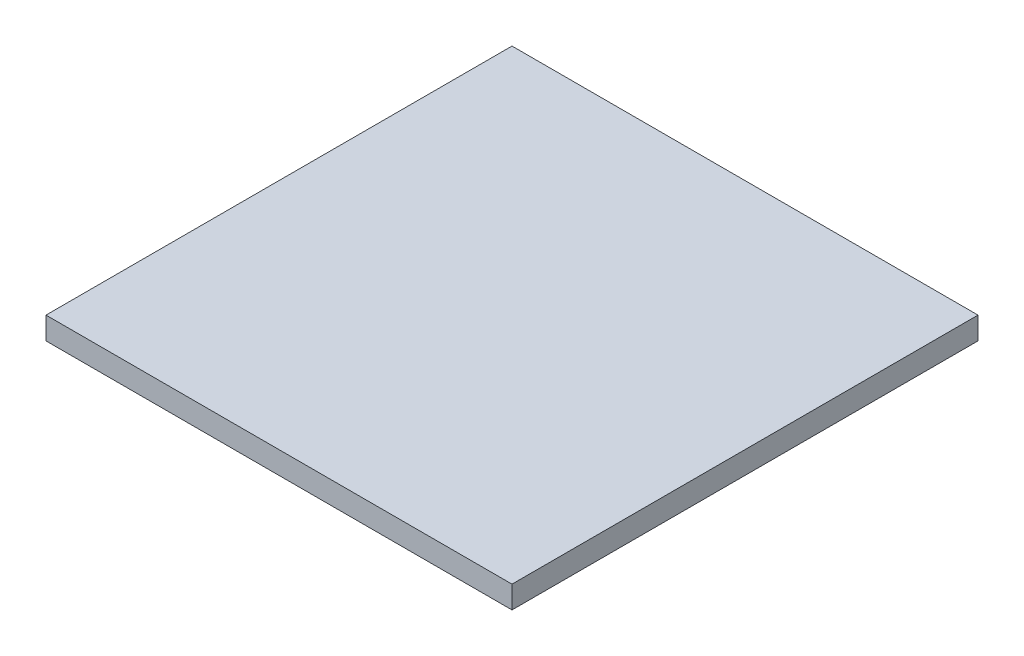
from build123d import *

# Parameters (mm, degrees)
SKETCH1_W           = 250
SKETCH1_H           = 250
BOSS_EXTRUDE1_DEPTH = 12
SKETCH2_R           = 3.5
CUT_EXTRUDE1_DEPTH  = 3


with BuildPart() as part:
    # Sketch1 → Boss-Extrude1 (new body)
    with BuildSketch(Plane(origin=(0, 0, 0), x_dir=(1, 0, 0), z_dir=(0, 1, 0))):
        Rectangle(SKETCH1_W, SKETCH1_H)
    extrude(amount=BOSS_EXTRUDE1_DEPTH)

    # Sketch2 → Cut-Extrude1 (cut)
    with BuildSketch(Plane.XZ):
        with Locations((-97.5, 45.5)):
            Circle(SKETCH2_R)
        with Locations((-73.5, 45.5)):
            Circle(SKETCH2_R)
        with Locations((-97.5, 27.5)):
            Circle(SKETCH2_R)
        with Locations((-73.5, 27.5)):
            Circle(SKETCH2_R)
        with Locations((-73.5, -27.5)):
            Circle(SKETCH2_R)
        with Locations((-97.5, -27.5)):
            Circle(SKETCH2_R)
        with Locations((-73.5, -45.5)):
            Circle(SKETCH2_R)
        with Locations((-97.5, -45.5)):
            Circle(SKETCH2_R)
        with Locations((97.5, -45.5)):
            Circle(SKETCH2_R)
        with Locations((73.5, -45.5)):
            Circle(SKETCH2_R)
        with Locations((97.5, -27.5)):
            Circle(SKETCH2_R)
        with Locations((73.5, -27.5)):
            Circle(SKETCH2_R)
        with Locations((73.5, 27.5)):
            Circle(SKETCH2_R)
        with Locations((97.5, 27.5)):
            Circle(SKETCH2_R)
        with Locations((73.5, 45.5)):
            Circle(SKETCH2_R)
        with Locations((97.5, 45.5)):
            Circle(SKETCH2_R)
    extrude(amount=-CUT_EXTRUDE1_DEPTH, mode=Mode.SUBTRACT)


solid = part.part
